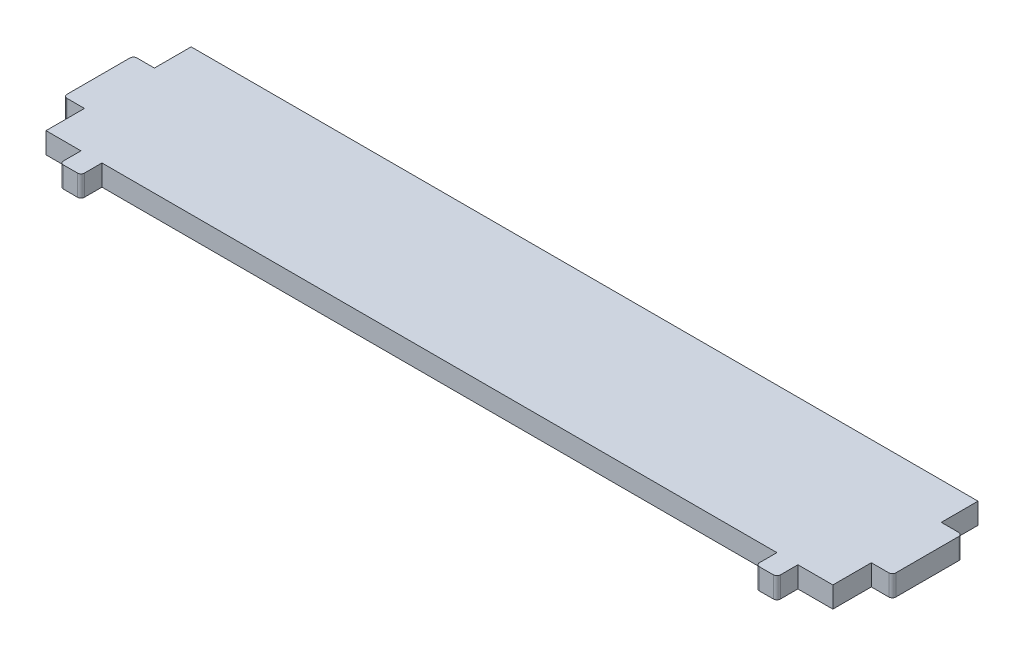
from build123d import *

# Parameters (mm, degrees)
SKETCH_1_W      = 3
SKETCH_1_H      = 3
EXTRUDE_1_DEPTH = 3
FILLET_1_R      = 0.5


with BuildPart() as part:
    # Эскиз1 → Бобышка-Вытянуть1 (new body)
    with BuildSketch(Plane(origin=(0, 0, 0), x_dir=(1, 0, 0), z_dir=(0, 1, 0))):
        Polygon((-56.25, -20.75), (56.25, -20.75), (56.25, -15.25), (59.25, -15.25), (59.25, -5.25), (56.25, -5.25), (56.25, 0), (-56.25, 0), (-56.25, -5.25), (-59.25, -5.25), (-59.25, -15.25), (-56.25, -15.25), align=None)
        with Locations((49.75, -22.25)):
            Rectangle(SKETCH_1_W, SKETCH_1_H)
        with Locations((-49.75, -22.25)):
            Rectangle(SKETCH_1_W, SKETCH_1_H)
    extrude(amount=EXTRUDE_1_DEPTH)

    # Скругление1
    fillet_1_edges = [part.edges().sort_by_distance(p)[0] for p in [
        (-59.25, 1.5, 15.25),
        (-59.25, 1.5, 5.25),
        (59.25, 1.5, 5.25),
        (59.25, 1.5, 15.25),
        (51.25, 1.5, 23.75),
        (48.25, 1.5, 23.75),
        (-48.25, 1.5, 23.75),
        (-51.25, 1.5, 23.75),
    ]]
    fillet(fillet_1_edges, radius=FILLET_1_R)


solid = part.part
